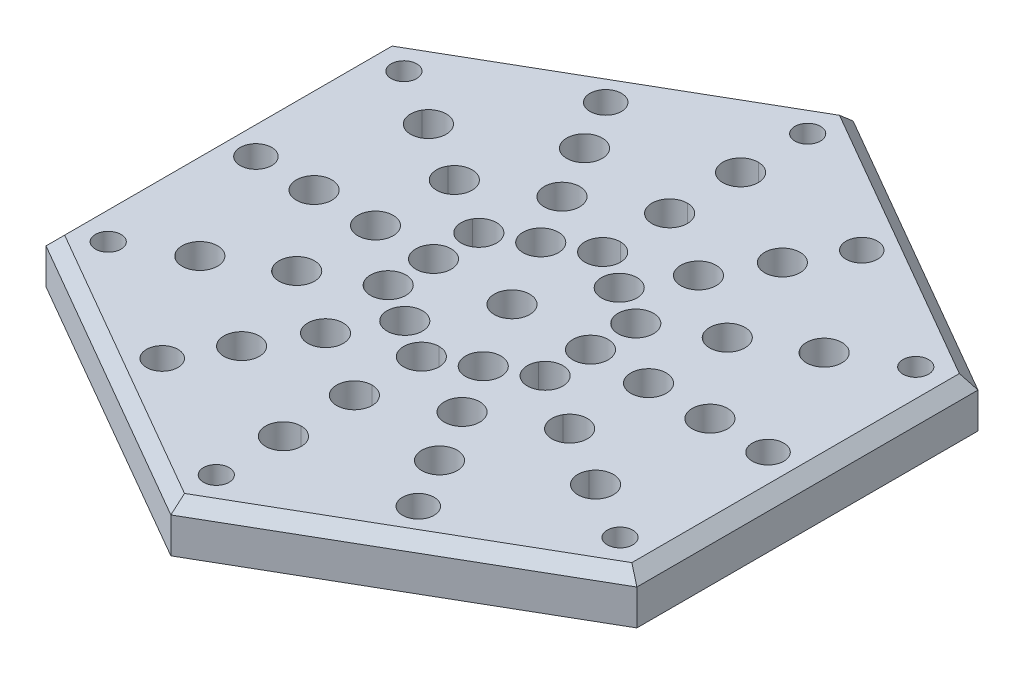
from build123d import *

# Parameters (mm, degrees)
EXTRUDE_1_DEPTH          = 12
CHAMFER_1_SIZE           = 3
SKETCH_2_R               = 3.25
CUT_EXTRUDE_1_DEPTH      = 13
PATTERN_CIRCULAR_1_COUNT = 6
SKETCH_4_R               = 4
CUT_EXTRUDE_2_DEPTH      = 13
PATTERN_CIRCULAR_2_COUNT = 6
SKETCH_5_R               = 4.5
CUT_EXTRUDE_3_DEPTH      = 13
SKETCH_9_R               = 4.5
CUT_EXTRUDE_5_DEPTH      = 13
PATTERN_CIRCULAR_3_COUNT = 6


with BuildPart() as part:
    # 草圖1 → 填料-伸長1 (new body)
    with BuildSketch(Plane(origin=(0, 0, 0), x_dir=(1, 0, 0), z_dir=(0, 1, 0))):
        Polygon((75, 43.301270189), (0, 86.602540378), (-75, 43.301270189), (-75, -43.301270189), (0, -86.602540378), (75, -43.301270189), align=None)
    extrude(amount=EXTRUDE_1_DEPTH)

    # 導角1
    chamfer_1_edges = [part.edges().sort_by_distance(p)[0] for p in [
        (-37.5, 12, -64.951905284),
        (-75, 12, 0),
        (-37.5, 12, 64.951905284),
        (37.5, 12, 64.951905284),
        (75, 12, 0),
        (37.5, 12, -64.951905284),
    ]]
    chamfer(chamfer_1_edges, length=CHAMFER_1_SIZE)

    # 草圖2 → 除料-伸長1 (cut, through all)
    with BuildSketch(Plane.XZ):
        with Locations((65, -37.5)):
            Circle(SKETCH_2_R)
    cut_extrude_1 = extrude(amount=-CUT_EXTRUDE_1_DEPTH, mode=Mode.SUBTRACT)

    # 環狀複製排列1: 除料-伸長1 ×6 about axis
    pattern_circular_1_axis = Axis((0, 0, 0), (0, 1, 0))
    for i in range(1, PATTERN_CIRCULAR_1_COUNT):
        add(cut_extrude_1.rotate(pattern_circular_1_axis, i * 360 / PATTERN_CIRCULAR_1_COUNT), mode=Mode.SUBTRACT)

    # 草圖4 → 除料-伸長2 (cut, through all)
    with BuildSketch(Plane.XZ):
        with Locations((65, 0)):
            Circle(SKETCH_4_R)
    cut_extrude_2 = extrude(amount=-CUT_EXTRUDE_2_DEPTH, mode=Mode.SUBTRACT)

    # 環狀複製排列2: 除料-伸長2 ×6 about axis
    pattern_circular_2_axis = Axis((0, 0, 0), (0, 1, 0))
    for i in range(1, PATTERN_CIRCULAR_2_COUNT):
        add(cut_extrude_2.rotate(pattern_circular_2_axis, i * 360 / PATTERN_CIRCULAR_2_COUNT), mode=Mode.SUBTRACT)

    # 草圖5 → 除料-伸長3 (cut, through all)
    with BuildSketch(Plane.XZ):
        Circle(SKETCH_5_R)
    extrude(amount=-CUT_EXTRUDE_3_DEPTH, mode=Mode.SUBTRACT)

    # 草圖9 → 除料-伸長5 (cut, through all)
    with BuildSketch(Plane.XZ):
        with Locations((0, 23.006385047)):
            Circle(SKETCH_9_R)
        with Locations((9.960213319, 17.257980865)):
            Circle(SKETCH_9_R)
        with Locations((19.920426639, 11.509576684)):
            Circle(SKETCH_9_R)
        with Locations((34.644220241, 20.016655103)):
            Circle(SKETCH_9_R)
        with Locations((50.23411935, 29.024149899)):
            Circle(SKETCH_9_R)
        with Locations((25.117059675, 43.52012566)):
            Circle(SKETCH_9_R)
        with Locations((17.326919147, 30.011104301)):
            Circle(SKETCH_9_R)
        with Locations((0, 40.011104429)):
            Circle(SKETCH_9_R)
        with Locations((0, 58.016101422)):
            Circle(SKETCH_9_R)
    cut_extrude_5 = extrude(amount=-CUT_EXTRUDE_5_DEPTH, mode=Mode.SUBTRACT)

    # 環狀複製排列3: 除料-伸長5 ×6 about axis
    pattern_circular_3_axis = Axis((0, 0, 0), (0, 1, 0))
    for i in range(1, PATTERN_CIRCULAR_3_COUNT):
        add(cut_extrude_5.rotate(pattern_circular_3_axis, i * 360 / PATTERN_CIRCULAR_3_COUNT), mode=Mode.SUBTRACT)


solid = part.part
